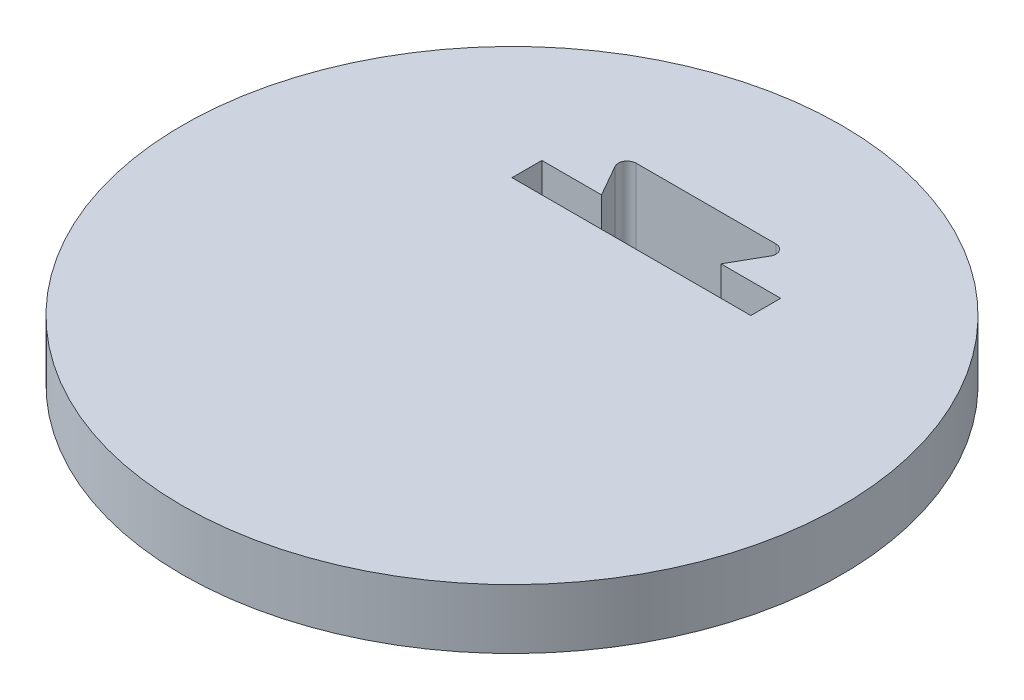
from build123d import *

# Parameters (mm, degrees)
SKETCH1_R           = 17.526
BOSS_EXTRUDE1_DEPTH = 3.175
CUT_EXTRUDE2_DEPTH  = 4.572
CUT_EXTRUDE3_DEPTH  = 4.064


with BuildPart() as part:
    # Sketch1 → Boss-Extrude1 (new body)
    with BuildSketch(Plane(origin=(0, 0, 0), x_dir=(1, 0, 0), z_dir=(0, 1, 0))):
        Circle(SKETCH1_R)
    extrude(amount=-BOSS_EXTRUDE1_DEPTH)

    # Sketch2 → Revolve2 (revolve)
    with BuildSketch(Plane.XY):
        with BuildLine():
            Line((-17.526, -3.175), (0, -3.175))
            Line((0, -3.175), (0, -4.7625))
            ThreePointArc((0, -4.7625), (-8.802377367, -4.403476128), (-17.526, -3.175))
        make_face()
    revolve(axis=Axis((0, 7.394642586, 0), (0, -1, 0)))

    # Sketch4 → Cut-Extrude2 (cut)
    with BuildSketch(Plane(origin=(0, 0, 0), x_dir=(1, 0, 0), z_dir=(0, 1, 0))):
        with BuildLine():
            Line((-4.128730565, 9.60699682), (-3.175, 7.9375))
            Line((-3.175, 7.9375), (3.175, 7.9375))
            Line((3.175, 7.9375), (4.128730565, 9.60699682))
            ThreePointArc((4.128730565, 9.60699682), (4.127101881, 10.081811553), (3.715626661, 10.31875))
            Line((3.715626661, 10.31875), (-3.715626661, 10.31875))
            ThreePointArc((-3.715626661, 10.31875), (-4.127101881, 10.081811553), (-4.128730565, 9.60699682))
        make_face()
    extrude(amount=-CUT_EXTRUDE2_DEPTH, mode=Mode.SUBTRACT)

    # Sketch4_4 → Cut-Extrude3 (cut)
    with BuildSketch(Plane(origin=(0, 0, 0), x_dir=(1, 0, 0), z_dir=(0, 1, 0))):
        Polygon((3.175, 7.9375), (-3.175, 7.9375), (-6.35, 7.9375), (-6.35, 6.35), (6.35, 6.35), (6.35, 7.9375), align=None)
    extrude(amount=-CUT_EXTRUDE3_DEPTH, mode=Mode.SUBTRACT)


solid = part.part
